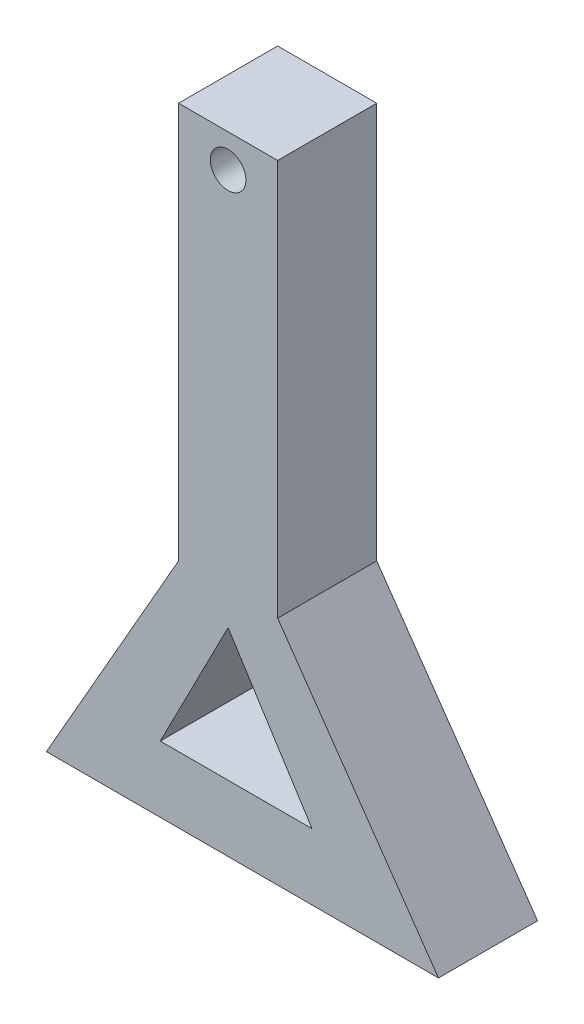
from build123d import *

# Parameters (mm, degrees)
SALIENTE_EXTRUIR1_DEPTH = 10
CROQUIS2_R              = 2.5
CORTAR_EXTRUIR1_DEPTH   = 10
CROQUIS4_W              = 15
CROQUIS4_H              = 60
SALIENTE_EXTRUIR2_DEPTH = 15
SALIENTE_EXTRUIR3_DEPTH = 15
CROQUIS6_R              = 2.7
CORTAR_EXTRUIR2_DEPTH   = 15


with BuildPart() as part:
    # Croquis1 → Saliente-Extruir1 (new body)
    with BuildSketch(Plane.XY):
        Polygon((-7.5, 0), (-27.5, -35), (-7.5, -35), (11.843788115, -35), (31.843788115, -35), (7.5, 0), (7.5, 34.865095039), (-7.5, 34.865095039), align=None)
        Polygon((-10.268203217, -25), (0, -5), (12.707404341, -25), align=None, mode=Mode.SUBTRACT)
    extrude(amount=SALIENTE_EXTRUIR1_DEPTH)

    # Croquis2 → Cortar-Extruir1 (cut)
    with BuildSketch(Plane.XY.offset(10)):
        with Locations((0, 28.865095039)):
            Circle(CROQUIS2_R)
    extrude(amount=-CORTAR_EXTRUIR1_DEPTH, mode=Mode.SUBTRACT)

    # Croquis4 → Saliente-Extruir2 (add)
    with BuildSketch(Plane.XY.offset(10)):
        with Locations((0, 30)):
            Rectangle(CROQUIS4_W, CROQUIS4_H)
    extrude(amount=-SALIENTE_EXTRUIR2_DEPTH)

    # Croquis5 → Saliente-Extruir3 (add)
    with BuildSketch(Plane.XY.offset(10)):
        Polygon((-7.5, 0), (-27.5, -35), (31.843788115, -35), (7.5, 0), (-0.734678119, 11.839313291), align=None)
        Polygon((12.707404341, -25), (-10.268203217, -25), (0, -5), align=None, mode=Mode.SUBTRACT)
    extrude(amount=-SALIENTE_EXTRUIR3_DEPTH)

    # Croquis6 → Cortar-Extruir2 (cut)
    with BuildSketch(Plane.XY.offset(10)):
        with Locations((0, 55)):
            Circle(CROQUIS6_R)
    extrude(amount=-CORTAR_EXTRUIR2_DEPTH, mode=Mode.SUBTRACT)


solid = part.part
